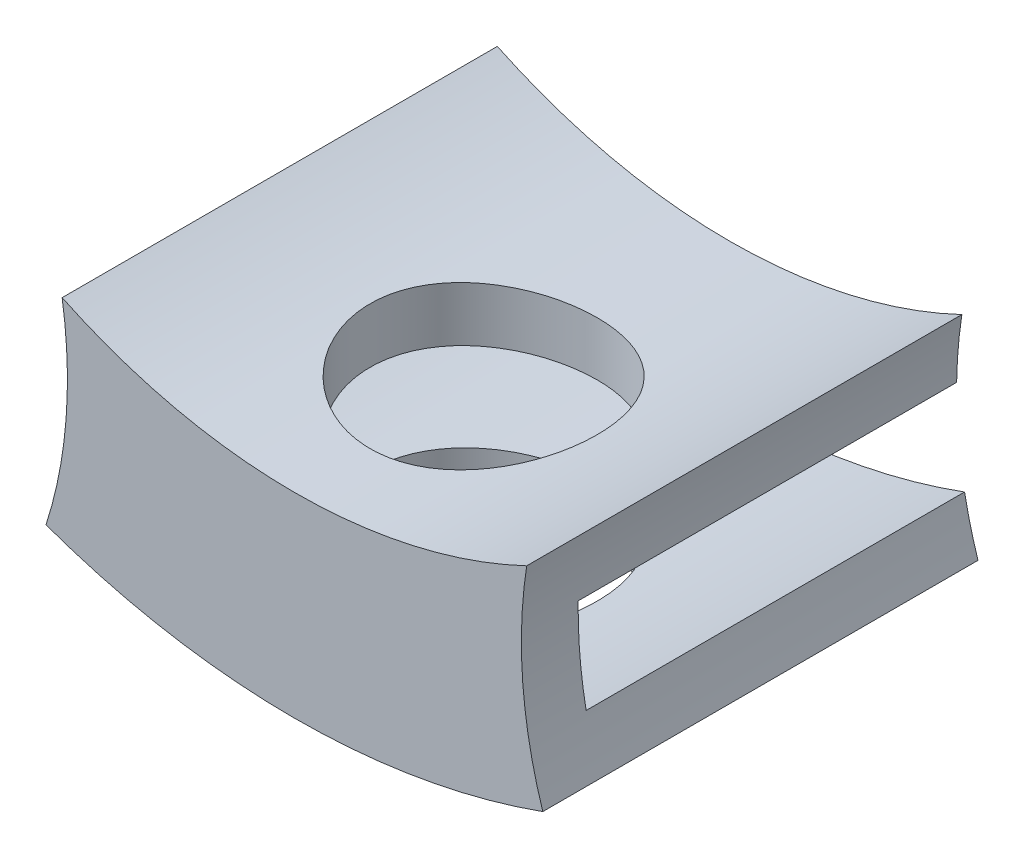
from build123d import *

# Parameters (mm, degrees)
BOSS_EXTRUDE1_DEPTH = 3
BOSS_EXTRUDE2_DEPTH = 20
SKETCH3_R           = 6
CUT_EXTRUDE1_DEPTH  = 58


with BuildPart() as part:
    # Sketch1 → Boss-Extrude1 (new body)
    with BuildSketch(Plane.XY):
        with BuildLine():
            ThreePointArc((12.275451386, 39.110148544), (12.067880772, 33.648168724), (13.127719813, 28.28598164))
            ThreePointArc((13.127719813, 28.28598164), (-5.7809e-05, 26.00056132), (-13.127971261, 28.285201272))
            ThreePointArc((-13.127971261, 28.285201272), (-12.06796259, 33.647129894), (-12.275256819, 39.10889939))
            ThreePointArc((-12.275256819, 39.10889939), (0.000238569, 36.332719941), (12.275451386, 39.110148544))
        make_face()
    extrude(amount=BOSS_EXTRUDE1_DEPTH)

    # Sketch2 → Boss-Extrude2 (add)
    with BuildSketch(Plane(origin=(0, 0, 0), x_dir=(-1, 0, 0), z_dir=(0, 0, -1))):
        with BuildLine():
            ThreePointArc((-0.000238569, 33.482719941), (6.116423648, 34.084515432), (11.998357864, 35.867368305))
            ThreePointArc((11.998357864, 35.867368305), (12.080645356, 37.492931332), (12.275256819, 39.10889939))
            ThreePointArc((12.275256819, 39.10889939), (-0.000238569, 36.332719941), (-12.275451386, 39.110148544))
            ThreePointArc((-12.275451386, 39.110148544), (-12.080742195, 37.494064654), (-11.998373995, 35.868378864))
            ThreePointArc((-11.998373995, 35.868378864), (-6.116717522, 34.085055957), (-0.000238569, 33.482719941))
        make_face()
        with BuildLine():
            ThreePointArc((-13.127719813, 28.28598164), (5.7809e-05, 26.00056132), (13.127971261, 28.285201272))
            ThreePointArc((13.127971261, 28.285201272), (12.730383089, 29.661389101), (12.417381714, 31.059244398))
            ThreePointArc((12.417381714, 31.059244398), (5.905e-06, 28.850561321), (-12.417221823, 31.060076762))
            ThreePointArc((-12.417221823, 31.060076762), (-12.730176217, 29.662196758), (-13.127719813, 28.28598164))
        make_face()
    extrude(amount=BOSS_EXTRUDE2_DEPTH)

    # Sketch3 → Cut-Extrude1 (cut)
    with BuildSketch(Plane(origin=(0, 0, 0), x_dir=(1, 0, 0), z_dir=(0, 1, 0))):
        with Locations((9.7284e-05, 7)):
            Circle(SKETCH3_R)
    extrude(amount=CUT_EXTRUDE1_DEPTH, mode=Mode.SUBTRACT)


solid = part.part
